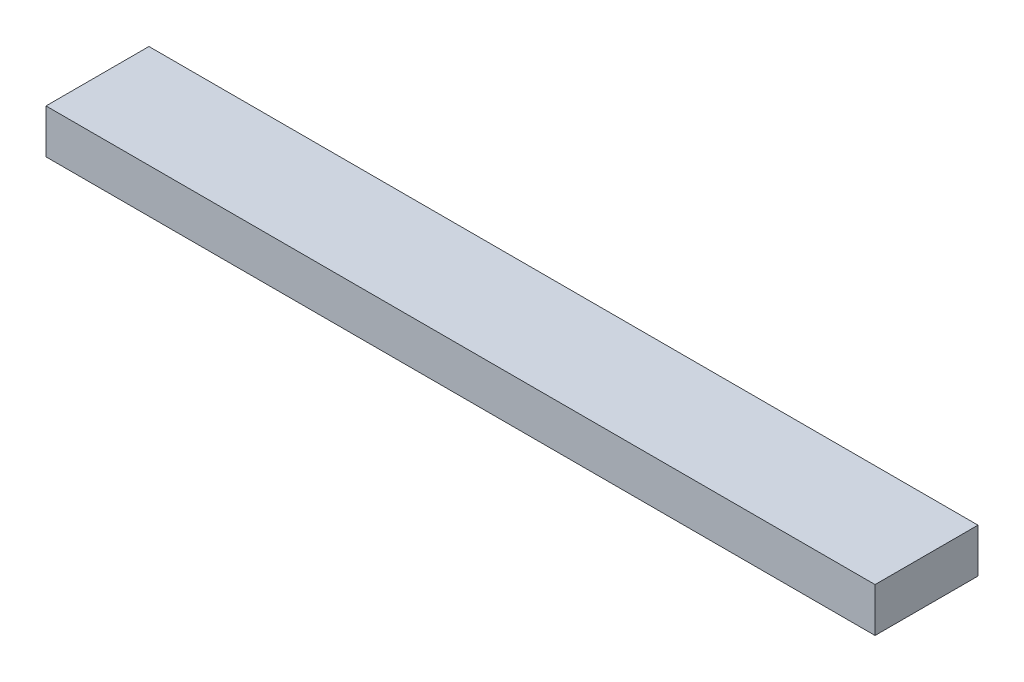
from build123d import *

# Parameters (mm, degrees)
SKETCH1_W           = 715.9625
SKETCH1_H           = 88.9
BOSS_EXTRUDE1_DEPTH = 38.1


with BuildPart() as part:
    # Sketch1 → Boss-Extrude1 (new body)
    with BuildSketch(Plane(origin=(0, 0, 0), x_dir=(1, 0, 0), z_dir=(0, 1, 0))):
        with Locations((357.98125, 44.45)):
            Rectangle(SKETCH1_W, SKETCH1_H)
    extrude(amount=BOSS_EXTRUDE1_DEPTH)


solid = part.part
